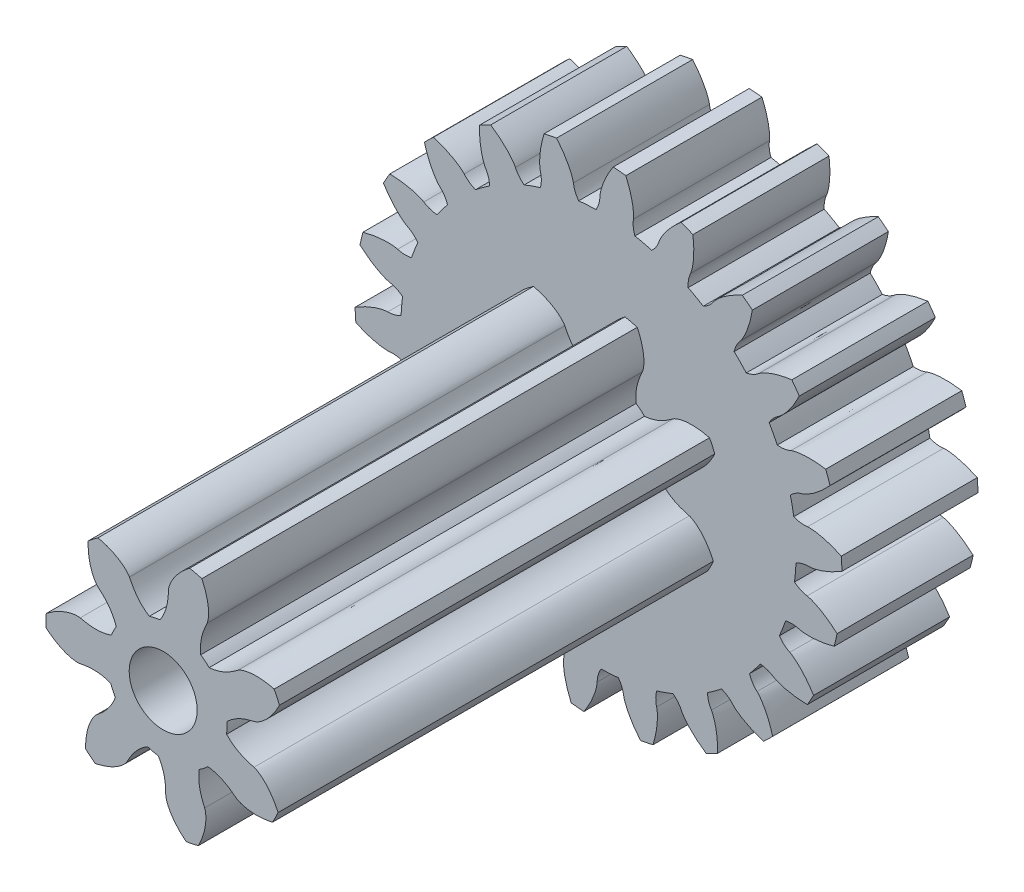
from build123d import *

# Parameters (mm, degrees)
EXTRUDE_1_DEPTH     = 10
EXTRUDE_2_DEPTH     = 32
SKETCH_5_R          = 2.5
CUT_EXTRUDE_1_DEPTH = 42


with BuildPart() as part:
    # 草图3 → 凸台-拉伸1 (new body)
    with BuildSketch(Plane.XY):
        with BuildLine():
            ThreePointArc((-8.005629463, 12.119633736), (-8.530243258, 11.756299373), (-9.038391722, 11.370272648))
            add(Edge.make_bspline(
                [(-9.038391722, 11.370272648), (-9.199749688, 11.431587767), (-9.351710074, 11.509202907), (-9.633739232, 11.702404006), (-9.763643975, 11.818787161), (-9.875892363, 11.950349138)],
                knots=[0, 0, 0, 0, 0.5, 0.5, 1, 1, 1, 1], degree=3))
            add(Edge.make_bspline(
                [(-9.875892363, 11.950349138), (-9.911367886, 11.991928621), (-9.950605534, 12.028738211), (-10.030196962, 12.100942279), (-10.071171913, 12.135549192), (-10.196572985, 12.2362304), (-10.283429657, 12.29922307), (-10.55106675, 12.47924093), (-10.738275466, 12.586937348), (-11.312628385, 12.880499231), (-11.714900374, 13.038200827), (-12.126147124, 13.16687343)],
                knots=[0, 0, 0, 0, 0.0625, 0.0625, 0.125, 0.125, 0.25, 0.25, 0.5, 0.5, 1, 1, 1, 1], degree=3))
            ThreePointArc((-12.126147124, 13.16687343), (-12.46716641, 12.84444478), (-12.799615589, 12.513186675))
            add(Edge.make_bspline(
                [(-12.799615589, 12.513186675), (-12.683196746, 12.098072887), (-12.53754001, 11.691181633), (-12.260711625, 11.107480816), (-12.158558163, 10.917204496), (-11.987275836, 10.645454457), (-11.927080489, 10.557003244), (-11.830304905, 10.428783255), (-11.796951142, 10.386796244), (-11.727094074, 10.304987565), (-11.691435842, 10.2645849), (-11.650698485, 10.227674188)],
                knots=[0, 0, 0, 0, 0.5, 0.5, 0.75, 0.75, 0.875, 0.875, 0.9375, 0.9375, 1, 1, 1, 1], degree=3))
            add(Edge.make_bspline(
                [(-11.650698485, 10.227674188), (-11.522536977, 10.111551468), (-11.412476818, 9.981355023), (-11.227133323, 9.693923293), (-11.152382825, 9.536553925), (-11.09584062, 9.373256955)],
                knots=[0, 0, 0, 0, 0.5, 0.5, 1, 1, 1, 1], degree=3))
            ThreePointArc((-11.09584062, 9.373256955), (-11.496840751, 8.876839401), (-11.875649335, 8.363287504))
            add(Edge.make_bspline(
                [(-11.875649335, 8.363287504), (-12.047745635, 8.376659138), (-12.21541727, 8.408318131), (-12.540453305, 8.514236432), (-12.697884916, 8.589306856), (-12.842651749, 8.683915623)],
                knots=[0, 0, 0, 0, 0.5, 0.5, 1, 1, 1, 1], degree=3))
            add(Edge.make_bspline(
                [(-12.842651749, 8.683915623), (-12.888404557, 8.713816235), (-12.936423265, 8.738080255), (-13.033132917, 8.784936055), (-13.082197989, 8.806597167), (-13.230884611, 8.867870514), (-13.331970063, 8.903841186), (-13.639482865, 9.001164976), (-13.849449901, 9.051756142), (-14.48324343, 9.17161279), (-14.913650252, 9.209593247), (-15.34448988, 9.217192107)],
                knots=[0, 0, 0, 0, 0.0625, 0.0625, 0.125, 0.125, 0.25, 0.25, 0.5, 0.5, 1, 1, 1, 1], degree=3))
            ThreePointArc((-15.34448988, 9.217192107), (-15.580856841, 8.811747847), (-15.806513299, 8.400246266))
            add(Edge.make_bspline(
                [(-15.806513299, 8.400246266), (-15.577859168, 8.034746481), (-15.32346804, 7.685373426), (-14.893405626, 7.203308163), (-14.741783063, 7.049519327), (-14.50087804, 6.837032881), (-14.418201441, 6.769123553), (-14.289222203, 6.673362207), (-14.245390394, 6.642472806), (-14.15531486, 6.583658964), (-14.109718291, 6.554938976), (-14.060232134, 6.531000446)],
                knots=[0, 0, 0, 0, 0.5, 0.5, 0.75, 0.75, 0.875, 0.875, 0.9375, 0.9375, 1, 1, 1, 1], degree=3))
            add(Edge.make_bspline(
                [(-14.060232134, 6.531000446), (-13.904546516, 6.455688782), (-13.76226399, 6.361773737), (-13.503449332, 6.138202309), (-13.387390681, 6.008267155), (-13.287132759, 5.86751464)],
                knots=[0, 0, 0, 0, 0.5, 0.5, 1, 1, 1, 1], degree=3))
            ThreePointArc((-13.287132759, 5.86751464), (-13.532032581, 5.278230692), (-13.750812466, 4.678758546))
            add(Edge.make_bspline(
                [(-13.750812466, 4.678758546), (-13.919704881, 4.643103404), (-14.089504006, 4.626241426), (-14.431214431, 4.636296059), (-14.603418739, 4.663971993), (-14.768975867, 4.713962911)],
                knots=[0, 0, 0, 0, 0.5, 0.5, 1, 1, 1, 1], degree=3))
            add(Edge.make_bspline(
                [(-14.768975867, 4.713962911), (-14.821299342, 4.729762282), (-14.874208918, 4.739515005), (-14.980201955, 4.757226558), (-15.033382186, 4.764187015), (-15.193308653, 4.781088498), (-15.300433543, 4.787123042), (-15.622909196, 4.793868167), (-15.83862427, 4.783255485), (-16.480512228, 4.719696825), (-16.90418488, 4.634879193), (-17.319713322, 4.520788695)],
                knots=[0, 0, 0, 0, 0.0625, 0.0625, 0.125, 0.125, 0.25, 0.25, 0.5, 0.5, 1, 1, 1, 1], degree=3))
            ThreePointArc((-17.319713322, 4.520788695), (-17.432278913, 4.065175509), (-17.532861306, 3.606767863))
            add(Edge.make_bspline(
                [(-17.532861306, 3.606767863), (-17.210496085, 3.3204927), (-16.867979821, 3.056941972), (-16.319524478, 2.715566322), (-16.130716372, 2.610724027), (-15.839705346, 2.474715564), (-15.741245461, 2.43284973), (-15.5905117, 2.377305042), (-15.539752837, 2.360015726), (-15.436756221, 2.328961468), (-15.384915278, 2.31425088), (-15.330689394, 2.30522389)],
                knots=[0, 0, 0, 0, 0.5, 0.5, 0.75, 0.75, 0.875, 0.875, 0.9375, 0.9375, 1, 1, 1, 1], degree=3))
            add(Edge.make_bspline(
                [(-15.330689394, 2.30522389), (-15.16009239, 2.276824585), (-14.99711438, 2.226799379), (-14.685796185, 2.08520068), (-14.537831761, 1.993226313), (-14.401980423, 1.886421184)],
                knots=[0, 0, 0, 0, 0.5, 0.5, 1, 1, 1, 1], degree=3))
            ThreePointArc((-14.401980423, 1.886421184), (-14.470939608, 1.252011124), (-14.51196655, 0.615184395))
            add(Edge.make_bspline(
                [(-14.51196655, 0.615184395), (-14.663972422, 0.533391045), (-14.822142921, 0.469374155), (-15.152844391, 0.382750552), (-15.325870425, 0.360789857), (-15.498805396, 0.362112958)],
                knots=[0, 0, 0, 0, 0.5, 0.5, 1, 1, 1, 1], degree=3))
            add(Edge.make_bspline(
                [(-15.498805396, 0.362112958), (-15.553460599, 0.362531117), (-15.606974626, 0.356982436), (-15.713664121, 0.344114858), (-15.766651166, 0.335810764), (-15.924861185, 0.306971127), (-16.029346892, 0.28258066), (-16.340660337, 0.19820067), (-16.544647496, 0.127243917), (-17.142627938, -0.114580906), (-17.525242983, -0.315325208), (-17.891796596, -0.54186213)],
                knots=[0, 0, 0, 0, 0.0625, 0.0625, 0.125, 0.125, 0.25, 0.25, 0.5, 0.5, 1, 1, 1, 1], degree=3))
            ThreePointArc((-17.891796596, -0.54186213), (-17.871441421, -1.010733172), (-17.838801163, -1.478909423))
            add(Edge.make_bspline(
                [(-17.838801163, -1.478909423), (-17.448840964, -1.662767652), (-17.045948195, -1.819144741), (-16.423532512, -1.992174552), (-16.212834973, -2.039576607), (-15.895293926, -2.088088492), (-15.789027391, -2.10051911), (-15.628750659, -2.11134724), (-15.575176923, -2.113635793), (-15.467603398, -2.114414635), (-15.413717926, -2.11392406), (-15.359145375, -2.107308196)],
                knots=[0, 0, 0, 0, 0.5, 0.5, 0.75, 0.75, 0.875, 0.875, 0.9375, 0.9375, 1, 1, 1, 1], degree=3))
            add(Edge.make_bspline(
                [(-15.359145375, -2.107308196), (-15.18745774, -2.0864944), (-15.016987755, -2.088577021), (-14.678387171, -2.136731507), (-14.510504172, -2.18329387), (-14.350065286, -2.247498897)],
                knots=[0, 0, 0, 0, 0.5, 0.5, 1, 1, 1, 1], degree=3))
            ThreePointArc((-14.350065286, -2.247498897), (-14.237497171, -2.875638939), (-14.097447411, -3.498228337))
            add(Edge.make_bspline(
                [(-14.097447411, -3.498228337), (-14.220252127, -3.619533484), (-14.353979967, -3.72551902), (-14.646881015, -3.901803128), (-14.806711236, -3.971621328), (-14.973013886, -4.019073234)],
                knots=[0, 0, 0, 0, 0.5, 0.5, 1, 1, 1, 1], degree=3))
            add(Edge.make_bspline(
                [(-14.973013886, -4.019073234), (-15.025572979, -4.034070163), (-15.075356068, -4.054470727), (-15.174098672, -4.096874982), (-15.222599837, -4.119770877), (-15.366276173, -4.19201522), (-15.459657887, -4.244854727), (-15.734588359, -4.413523867), (-15.910321778, -4.539076197), (-16.415949884, -4.939575975), (-16.726510126, -5.239983837), (-17.014392916, -5.560614507)],
                knots=[0, 0, 0, 0, 0.0625, 0.0625, 0.125, 0.125, 0.25, 0.25, 0.5, 0.5, 1, 1, 1, 1], degree=3))
            ThreePointArc((-17.014392916, -5.560614507), (-16.862766031, -6.004758263), (-16.69954744, -6.444774263))
            add(Edge.make_bspline(
                [(-16.69954744, -6.444774263), (-16.273584521, -6.511320458), (-15.842955223, -6.547855166), (-15.197003617, -6.538521292), (-14.981486107, -6.524642874), (-14.663140326, -6.481728036), (-14.557676222, -6.463716384), (-14.400841187, -6.428950725), (-14.348792805, -6.41605311), (-14.245357338, -6.386493439), (-14.193792817, -6.370841444), (-14.143294742, -6.349118705)],
                knots=[0, 0, 0, 0, 0.5, 0.5, 0.75, 0.75, 0.875, 0.875, 0.9375, 0.9375, 1, 1, 1, 1], degree=3))
            add(Edge.make_bspline(
                [(-14.143294742, -6.349118705), (-13.984425586, -6.280778017), (-13.820274091, -6.234749333), (-13.481822523, -6.185558416), (-13.307621832, -6.182936569), (-13.135593202, -6.199339983)],
                knots=[0, 0, 0, 0, 0.5, 0.5, 1, 1, 1, 1], degree=3))
            ThreePointArc((-13.135593202, -6.199339983), (-12.850617387, -6.770321838), (-12.540836923, -7.328235413))
            add(Edge.make_bspline(
                [(-12.540836923, -7.328235413), (-12.624491576, -7.479224937), (-12.722942923, -7.6185928), (-12.954314447, -7.870255924), (-13.088000362, -7.982275374), (-13.234197839, -8.074658014)],
                knots=[0, 0, 0, 0, 0.5, 0.5, 1, 1, 1, 1], degree=3))
            add(Edge.make_bspline(
                [(-13.234197839, -8.074658014), (-13.280402796, -8.10385507), (-13.322421817, -8.137454784), (-13.405217993, -8.205960376), (-13.445304001, -8.241593183), (-13.562806853, -8.351389424), (-13.637519341, -8.428397229), (-13.853793609, -8.667690949), (-13.987036411, -8.837667352), (-14.3593492, -9.364395974), (-14.572694895, -9.740130138), (-14.75858431, -10.128878968)],
                knots=[0, 0, 0, 0, 0.0625, 0.0625, 0.125, 0.125, 0.25, 0.25, 0.5, 0.5, 1, 1, 1, 1], degree=3))
            ThreePointArc((-14.75858431, -10.128878968), (-14.487969623, -10.512313551), (-14.2073957, -10.88852182))
            add(Edge.make_bspline(
                [(-14.2073957, -10.88852182), (-13.779939042, -10.832364805), (-13.35646024, -10.746097307), (-12.739303869, -10.555155923), (-12.536426334, -10.481121379), (-12.243066302, -10.350256523), (-12.146948704, -10.303261797), (-12.006261207, -10.225718857), (-11.959954828, -10.198679962), (-11.869037147, -10.141176527), (-11.823971028, -10.111631143), (-11.781638482, -10.076561376)],
                knots=[0, 0, 0, 0, 0.5, 0.5, 0.75, 0.75, 0.875, 0.875, 0.9375, 0.9375, 1, 1, 1, 1], degree=3))
            add(Edge.make_bspline(
                [(-11.781638482, -10.076561376), (-11.64845844, -9.966230353), (-11.503924013, -9.875819334), (-11.193040795, -9.733268168), (-11.026635115, -9.681674519), (-10.856953477, -9.648947414)],
                knots=[0, 0, 0, 0, 0.5, 0.5, 1, 1, 1, 1], degree=3))
            ThreePointArc((-10.856953477, -9.648947414), (-10.422657007, -10.116513526), (-9.968242411, -10.564552439))
            add(Edge.make_bspline(
                [(-9.968242411, -10.564552439), (-10.005969798, -10.732994065), (-10.061168709, -10.8944535), (-10.212266366, -11.201107391), (-10.308977536, -11.34625294), (-10.42322579, -11.476082024)],
                knots=[0, 0, 0, 0, 0.5, 0.5, 1, 1, 1, 1], degree=3))
            add(Edge.make_bspline(
                [(-10.42322579, -11.476082024), (-10.45933336, -11.517113834), (-10.490184183, -11.56119065), (-10.550326276, -11.650247663), (-10.578749597, -11.695730625), (-10.660559582, -11.834183725), (-10.710550084, -11.929121113), (-10.850646893, -12.219653259), (-10.930604538, -12.420283259), (-11.139439442, -13.030568304), (-11.23828659, -13.451189022), (-11.307122977, -13.876561894)],
                knots=[0, 0, 0, 0, 0.0625, 0.0625, 0.125, 0.125, 0.25, 0.25, 0.5, 0.5, 1, 1, 1, 1], degree=3))
            ThreePointArc((-11.307122977, -13.876561894), (-10.939444081, -14.168223714), (-10.564245255, -14.450146096))
            add(Edge.make_bspline(
                [(-10.564245255, -14.450146096), (-10.169924855, -14.275835377), (-9.787904282, -14.073754553), (-9.249541485, -13.716674595), (-9.075739857, -13.588481764), (-8.831131858, -13.380268782), (-8.752147642, -13.308098216), (-8.639005349, -13.194060061), (-8.60219244, -13.155070417), (-8.531158153, -13.074281804), (-8.496241425, -13.033236623), (-8.46550394, -12.987660972)],
                knots=[0, 0, 0, 0, 0.5, 0.5, 0.75, 0.75, 0.875, 0.875, 0.9375, 0.9375, 1, 1, 1, 1], degree=3))
            add(Edge.make_bspline(
                [(-8.46550394, -12.987660972), (-8.368802467, -12.844277977), (-8.255594428, -12.716809185), (-7.997465468, -12.49244642), (-7.852335998, -12.396060778), (-7.698747951, -12.316854509)],
                knots=[0, 0, 0, 0, 0.5, 0.5, 1, 1, 1, 1], degree=3))
            ThreePointArc((-7.698747951, -12.316854509), (-7.150314943, -12.643125453), (-6.588080182, -12.944992257))
            add(Edge.make_bspline(
                [(-6.588080182, -12.944992257), (-6.576823855, -13.117239846), (-6.584298443, -13.28771037), (-6.642881198, -13.624511753), (-6.694782659, -13.791024573), (-6.767825977, -13.947782119)],
                knots=[0, 0, 0, 0, 0.5, 0.5, 1, 1, 1, 1], degree=3))
            add(Edge.make_bspline(
                [(-6.767825977, -13.947782119), (-6.79091094, -13.997324531), (-6.808094213, -14.048307607), (-6.84070987, -14.15070117), (-6.855167815, -14.202349528), (-6.894657175, -14.358242841), (-6.915875758, -14.463418549), (-6.968445297, -14.781651934), (-6.988640093, -14.996681681), (-7.017078549, -15.641081486), (-6.993419143, -16.072512569), (-6.939625785, -16.500048302)],
                knots=[0, 0, 0, 0, 0.0625, 0.0625, 0.125, 0.125, 0.25, 0.25, 0.5, 0.5, 1, 1, 1, 1], degree=3))
            ThreePointArc((-6.939625785, -16.500048302), (-6.504669838, -16.676308653), (-6.065242487, -16.841105473))
            add(Edge.make_bspline(
                [(-6.065242487, -16.841105473), (-5.736003839, -16.562762669), (-5.42639053, -16.261239906), (-5.010436259, -15.766949868), (-4.879790912, -15.59498417), (-4.703751632, -15.326291239), (-4.64829963, -15.234791664), (-4.571868655, -15.093496988), (-4.54753158, -15.045715303), (-4.502135463, -14.948186526), (-4.480196872, -14.898966784), (-4.463544616, -14.846577516)],
                knots=[0, 0, 0, 0, 0.5, 0.5, 0.75, 0.75, 0.875, 0.875, 0.9375, 0.9375, 1, 1, 1, 1], degree=3))
            add(Edge.make_bspline(
                [(-4.463544616, -14.846577516), (-4.41115589, -14.681758587), (-4.33844568, -14.527558786), (-4.153983053, -14.239560957), (-4.041887319, -14.106191915), (-3.916835651, -13.986923303)],
                knots=[0, 0, 0, 0, 0.5, 0.5, 1, 1, 1, 1], degree=3))
            ThreePointArc((-3.916835651, -13.986923303), (-3.298696886, -14.145466548), (-2.674190877, -14.276705788))
            add(Edge.make_bspline(
                [(-2.674190877, -14.276705788), (-2.614862757, -14.438804866), (-2.574007475, -14.604475971), (-2.535329302, -14.9441392), (-2.538216307, -15.118529412), (-2.564137153, -15.289515857)],
                knots=[0, 0, 0, 0, 0.5, 0.5, 1, 1, 1, 1], degree=3))
            add(Edge.make_bspline(
                [(-2.564137153, -15.289515857), (-2.572329302, -15.343555239), (-2.57445294, -15.39731423), (-2.576899832, -15.504749027), (-2.576221106, -15.558378537), (-2.570190648, -15.719082514), (-2.560918307, -15.825975832), (-2.521701706, -16.14612908), (-2.48049759, -16.358138143), (-2.326235685, -16.984447267), (-2.181986468, -17.391736735), (-2.009921385, -17.786798926)],
                knots=[0, 0, 0, 0, 0.0625, 0.0625, 0.125, 0.125, 0.25, 0.25, 0.5, 0.5, 1, 1, 1, 1], degree=3))
            ThreePointArc((-2.009921385, -17.786798926), (-1.542925929, -17.833378244), (-1.074869845, -17.867698644))
            add(Edge.make_bspline(
                [(-1.074869845, -17.867698644), (-0.837385905, -17.507873432), (-0.62526289, -17.131336311), (-0.365415286, -16.539880631), (-0.288510329, -16.338073705), (-0.195301423, -16.030668729), (-0.167874025, -15.927252895), (-0.134346353, -15.770148553), (-0.124456757, -15.717445816), (-0.108376533, -15.611078075), (-0.101193413, -15.557671263), (-0.099975453, -15.502712646)],
                knots=[0, 0, 0, 0, 0.5, 0.5, 0.75, 0.75, 0.875, 0.875, 0.9375, 0.9375, 1, 1, 1, 1], degree=3))
            add(Edge.make_bspline(
                [(-0.099975453, -15.502712646), (-0.096143696, -15.329810432), (-0.069821865, -15.161371973), (0.026030365, -14.833070953), (0.096011032, -14.673523276), (0.182395378, -14.523854755)],
                knots=[0, 0, 0, 0, 0.5, 0.5, 1, 1, 1, 1], degree=3))
            ThreePointArc((0.182395378, -14.523854755), (0.820161974, -14.501826069), (1.456345468, -14.451805523))
            add(Edge.make_bspline(
                [(1.456345468, -14.451805523), (1.558938971, -14.590623787), (1.64481427, -14.738073785), (1.777619896, -15.053081366), (1.823981235, -15.221220913), (1.847282814, -15.392583951)],
                knots=[0, 0, 0, 0, 0.5, 0.5, 1, 1, 1, 1], degree=3))
            add(Edge.make_bspline(
                [(1.847282814, -15.392583951), (1.854647157, -15.446742354), (1.8677552, -15.498922025), (1.895675304, -15.602694327), (1.911435716, -15.653960246), (1.962497441, -15.806455606), (2.001509514, -15.906406674), (2.129335161, -16.202542872), (2.228600076, -16.394355538), (2.553064961, -16.951834141), (2.806217773, -17.301985823), (3.082614893, -17.632568883)],
                knots=[0, 0, 0, 0, 0.0625, 0.0625, 0.125, 0.125, 0.25, 0.25, 0.5, 0.5, 1, 1, 1, 1], degree=3))
            ThreePointArc((3.082614893, -17.632568883), (3.543816662, -17.545693588), (4.00258236, -17.446757133))
            add(Edge.make_bspline(
                [(4.00258236, -17.446757133), (4.129072055, -17.034600413), (4.226519831, -16.613553731), (4.309209461, -15.972848633), (4.326143645, -15.757549675), (4.328970946, -15.436336777), (4.326151734, -15.32938282), (4.314059892, -15.169196471), (4.308700813, -15.115842344), (4.294162419, -15.009252921), (4.286008135, -14.955985742), (4.271693127, -14.902910196)],
                knots=[0, 0, 0, 0, 0.5, 0.5, 0.75, 0.75, 0.875, 0.875, 0.9375, 0.9375, 1, 1, 1, 1], degree=3))
            add(Edge.make_bspline(
                [(4.271693127, -14.902910196), (4.226657488, -14.735932205), (4.204458503, -14.566900971), (4.203934958, -14.224893755), (4.226131141, -14.052093048), (4.266849819, -13.88414987)],
                knots=[0, 0, 0, 0, 0.5, 0.5, 1, 1, 1, 1], degree=3))
            ThreePointArc((4.266849819, -13.88414987), (4.872576188, -13.683333888), (5.468897364, -13.456105923))
            add(Edge.make_bspline(
                [(5.468897364, -13.456105923), (5.606444734, -13.560397142), (5.730382945, -13.677680511), (5.946556901, -13.942512404), (6.038410665, -14.090779619), (6.109046913, -14.248636437)],
                knots=[0, 0, 0, 0, 0.5, 0.5, 1, 1, 1, 1], degree=3))
            add(Edge.make_bspline(
                [(6.109046913, -14.248636437), (6.131371134, -14.298526268), (6.158648921, -14.344899334), (6.2146741, -14.436602126), (6.244239384, -14.481351194), (6.336195658, -14.61328367), (6.401786938, -14.698195047), (6.607865956, -14.946323002), (6.757149817, -15.102399748), (7.225531467, -15.545884229), (7.56707894, -15.810530918), (7.925416046, -16.049852974)],
                knots=[0, 0, 0, 0, 0.0625, 0.0625, 0.125, 0.125, 0.25, 0.25, 0.5, 0.5, 1, 1, 1, 1], degree=3))
            ThreePointArc((7.925416046, -16.049852974), (8.343460303, -15.836561185), (8.755769146, -15.612383119))
            add(Edge.make_bspline(
                [(8.755769146, -15.612383119), (8.761017154, -15.181285377), (8.735895052, -14.749839833), (8.634727685, -14.111791432), (8.59031919, -13.900442684), (8.502535835, -13.591444623), (8.469698408, -13.489617317), (8.412966661, -13.339326305), (8.392793068, -13.289643222), (8.34881387, -13.19146736), (8.325982793, -13.142655202), (8.297294535, -13.095762593)],
                knots=[0, 0, 0, 0, 0.5, 0.5, 0.75, 0.75, 0.875, 0.875, 0.9375, 0.9375, 1, 1, 1, 1], degree=3))
            add(Edge.make_bspline(
                [(8.297294535, -13.095762593), (8.207040019, -12.94823639), (8.138118647, -12.792306285), (8.041261742, -12.464300264), (8.013875239, -12.292245812), (8.005629463, -12.119633736)],
                knots=[0, 0, 0, 0, 0.5, 0.5, 1, 1, 1, 1], degree=3))
            ThreePointArc((8.005629463, -12.119633736), (8.530243259, -11.756299373), (9.038391722, -11.370272648))
            add(Edge.make_bspline(
                [(9.038391722, -11.370272648), (9.199749688, -11.431587767), (9.351710074, -11.509202907), (9.633739232, -11.702404006), (9.763643975, -11.818787161), (9.875892363, -11.950349138)],
                knots=[0, 0, 0, 0, 0.5, 0.5, 1, 1, 1, 1], degree=3))
            add(Edge.make_bspline(
                [(9.875892363, -11.950349138), (9.911367886, -11.991928621), (9.950605534, -12.028738211), (10.030196962, -12.100942279), (10.071171913, -12.135549191), (10.196572985, -12.2362304), (10.283429657, -12.29922307), (10.55106675, -12.47924093), (10.738275466, -12.586937348), (11.312628385, -12.880499231), (11.714900374, -13.038200827), (12.126147124, -13.16687343)],
                knots=[0, 0, 0, 0, 0.0625, 0.0625, 0.125, 0.125, 0.25, 0.25, 0.5, 0.5, 1, 1, 1, 1], degree=3))
            ThreePointArc((12.126147124, -13.16687343), (12.46716641, -12.84444478), (12.799615589, -12.513186675))
            add(Edge.make_bspline(
                [(12.799615589, -12.513186675), (12.683196746, -12.098072887), (12.53754001, -11.691181633), (12.260711625, -11.107480816), (12.158558163, -10.917204496), (11.987275836, -10.645454457), (11.927080489, -10.557003244), (11.830304905, -10.428783255), (11.796951142, -10.386796244), (11.727094074, -10.304987565), (11.691435842, -10.2645849), (11.650698485, -10.227674188)],
                knots=[0, 0, 0, 0, 0.5, 0.5, 0.75, 0.75, 0.875, 0.875, 0.9375, 0.9375, 1, 1, 1, 1], degree=3))
            add(Edge.make_bspline(
                [(11.650698485, -10.227674188), (11.522536977, -10.111551468), (11.412476818, -9.981355023), (11.227133323, -9.693923293), (11.152382825, -9.536553925), (11.09584062, -9.373256955)],
                knots=[0, 0, 0, 0, 0.5, 0.5, 1, 1, 1, 1], degree=3))
            ThreePointArc((11.09584062, -9.373256955), (11.496840751, -8.876839401), (11.875649335, -8.363287504))
            add(Edge.make_bspline(
                [(11.875649335, -8.363287504), (12.047745635, -8.376659138), (12.21541727, -8.408318131), (12.540453305, -8.514236432), (12.697884916, -8.589306856), (12.842651749, -8.683915624)],
                knots=[0, 0, 0, 0, 0.5, 0.5, 1, 1, 1, 1], degree=3))
            add(Edge.make_bspline(
                [(12.842651749, -8.683915624), (12.888404557, -8.713816235), (12.936423265, -8.738080255), (13.033132917, -8.784936055), (13.082197989, -8.806597167), (13.230884611, -8.867870514), (13.331970063, -8.903841186), (13.639482865, -9.001164976), (13.849449901, -9.051756142), (14.48324343, -9.17161279), (14.913650252, -9.209593247), (15.34448988, -9.217192107)],
                knots=[0, 0, 0, 0, 0.0625, 0.0625, 0.125, 0.125, 0.25, 0.25, 0.5, 0.5, 1, 1, 1, 1], degree=3))
            ThreePointArc((15.34448988, -9.217192107), (15.580856841, -8.811747847), (15.806513299, -8.400246266))
            add(Edge.make_bspline(
                [(15.806513299, -8.400246266), (15.577859168, -8.034746481), (15.32346804, -7.685373426), (14.893405626, -7.203308163), (14.741783063, -7.049519327), (14.50087804, -6.837032881), (14.418201441, -6.769123553), (14.289222203, -6.673362207), (14.245390394, -6.642472806), (14.15531486, -6.583658964), (14.109718291, -6.554938976), (14.060232134, -6.531000446)],
                knots=[0, 0, 0, 0, 0.5, 0.5, 0.75, 0.75, 0.875, 0.875, 0.9375, 0.9375, 1, 1, 1, 1], degree=3))
            add(Edge.make_bspline(
                [(14.060232134, -6.531000446), (13.904546516, -6.455688782), (13.76226399, -6.361773737), (13.503449332, -6.138202309), (13.387390681, -6.008267155), (13.287132759, -5.86751464)],
                knots=[0, 0, 0, 0, 0.5, 0.5, 1, 1, 1, 1], degree=3))
            ThreePointArc((13.287132759, -5.86751464), (13.532032581, -5.278230692), (13.750812466, -4.678758545))
            add(Edge.make_bspline(
                [(13.750812466, -4.678758545), (13.919704881, -4.643103403), (14.089504006, -4.626241426), (14.431214431, -4.636296059), (14.603418739, -4.663971993), (14.768975867, -4.71396291)],
                knots=[0, 0, 0, 0, 0.5, 0.5, 1, 1, 1, 1], degree=3))
            add(Edge.make_bspline(
                [(14.768975867, -4.71396291), (14.821299342, -4.729762281), (14.874208919, -4.739515005), (14.980201955, -4.757226558), (15.033382186, -4.764187015), (15.193308653, -4.781088498), (15.300433543, -4.787123042), (15.622909196, -4.793868167), (15.83862427, -4.783255485), (16.480512228, -4.719696825), (16.90418488, -4.634879193), (17.319713322, -4.520788695)],
                knots=[0, 0, 0, 0, 0.0625, 0.0625, 0.125, 0.125, 0.25, 0.25, 0.5, 0.5, 1, 1, 1, 1], degree=3))
            ThreePointArc((17.319713322, -4.520788695), (17.432278913, -4.065175509), (17.532861306, -3.606767863))
            add(Edge.make_bspline(
                [(17.532861306, -3.606767863), (17.210496085, -3.3204927), (16.867979821, -3.056941972), (16.319524478, -2.715566322), (16.130716372, -2.610724027), (15.839705346, -2.474715563), (15.741245461, -2.43284973), (15.5905117, -2.377305041), (15.539752837, -2.360015726), (15.436756221, -2.328961468), (15.384915278, -2.31425088), (15.330689394, -2.30522389)],
                knots=[0, 0, 0, 0, 0.5, 0.5, 0.75, 0.75, 0.875, 0.875, 0.9375, 0.9375, 1, 1, 1, 1], degree=3))
            add(Edge.make_bspline(
                [(15.330689394, -2.30522389), (15.16009239, -2.276824585), (14.99711438, -2.226799379), (14.685796185, -2.08520068), (14.537831761, -1.993226313), (14.401980424, -1.886421184)],
                knots=[0, 0, 0, 0, 0.5, 0.5, 1, 1, 1, 1], degree=3))
            ThreePointArc((14.401980424, -1.886421184), (14.470939608, -1.252011124), (14.511966551, -0.615184395))
            add(Edge.make_bspline(
                [(14.511966551, -0.615184395), (14.663972422, -0.533391045), (14.822142921, -0.469374154), (15.152844391, -0.382750552), (15.325870425, -0.360789857), (15.498805396, -0.362112957)],
                knots=[0, 0, 0, 0, 0.5, 0.5, 1, 1, 1, 1], degree=3))
            add(Edge.make_bspline(
                [(15.498805396, -0.362112957), (15.553460599, -0.362531117), (15.606974626, -0.356982436), (15.713664121, -0.344114858), (15.766651166, -0.335810764), (15.924861185, -0.306971127), (16.029346892, -0.28258066), (16.340660337, -0.19820067), (16.544647496, -0.127243917), (17.142627938, 0.114580906), (17.525242983, 0.315325208), (17.891796596, 0.54186213)],
                knots=[0, 0, 0, 0, 0.0625, 0.0625, 0.125, 0.125, 0.25, 0.25, 0.5, 0.5, 1, 1, 1, 1], degree=3))
            ThreePointArc((17.891796596, 0.54186213), (17.871441421, 1.010733172), (17.838801163, 1.478909423))
            add(Edge.make_bspline(
                [(17.838801163, 1.478909423), (17.448840964, 1.662767652), (17.045948195, 1.819144741), (16.423532512, 1.992174552), (16.212834973, 2.039576607), (15.895293926, 2.088088492), (15.789027391, 2.10051911), (15.628750659, 2.11134724), (15.575176923, 2.113635793), (15.467603398, 2.114414635), (15.413717926, 2.11392406), (15.359145375, 2.107308196)],
                knots=[0, 0, 0, 0, 0.5, 0.5, 0.75, 0.75, 0.875, 0.875, 0.9375, 0.9375, 1, 1, 1, 1], degree=3))
            add(Edge.make_bspline(
                [(15.359145375, 2.107308196), (15.18745774, 2.0864944), (15.016987755, 2.088577021), (14.67838717, 2.136731507), (14.510504172, 2.18329387), (14.350065286, 2.247498897)],
                knots=[0, 0, 0, 0, 0.5, 0.5, 1, 1, 1, 1], degree=3))
            ThreePointArc((14.350065286, 2.247498897), (14.237497171, 2.875638939), (14.097447411, 3.498228337))
            add(Edge.make_bspline(
                [(14.097447411, 3.498228337), (14.220252127, 3.619533484), (14.353979967, 3.72551902), (14.646881015, 3.901803128), (14.806711236, 3.971621329), (14.973013886, 4.019073234)],
                knots=[0, 0, 0, 0, 0.5, 0.5, 1, 1, 1, 1], degree=3))
            add(Edge.make_bspline(
                [(14.973013886, 4.019073234), (15.025572979, 4.034070163), (15.075356068, 4.054470727), (15.174098672, 4.096874982), (15.222599837, 4.119770877), (15.366276173, 4.19201522), (15.459657887, 4.244854727), (15.734588359, 4.413523868), (15.910321778, 4.539076197), (16.415949884, 4.939575975), (16.726510126, 5.239983837), (17.014392916, 5.560614508)],
                knots=[0, 0, 0, 0, 0.0625, 0.0625, 0.125, 0.125, 0.25, 0.25, 0.5, 0.5, 1, 1, 1, 1], degree=3))
            ThreePointArc((17.014392916, 5.560614508), (16.862766031, 6.004758263), (16.69954744, 6.444774263))
            add(Edge.make_bspline(
                [(16.69954744, 6.444774263), (16.273584521, 6.511320458), (15.842955223, 6.547855166), (15.197003617, 6.538521292), (14.981486107, 6.524642874), (14.663140326, 6.481728036), (14.557676222, 6.463716384), (14.400841187, 6.428950725), (14.348792805, 6.41605311), (14.245357338, 6.386493439), (14.193792817, 6.370841444), (14.143294742, 6.349118705)],
                knots=[0, 0, 0, 0, 0.5, 0.5, 0.75, 0.75, 0.875, 0.875, 0.9375, 0.9375, 1, 1, 1, 1], degree=3))
            add(Edge.make_bspline(
                [(14.143294742, 6.349118705), (13.984425586, 6.280778017), (13.820274091, 6.234749333), (13.481822523, 6.185558416), (13.307621832, 6.182936569), (13.135593202, 6.199339983)],
                knots=[0, 0, 0, 0, 0.5, 0.5, 1, 1, 1, 1], degree=3))
            ThreePointArc((13.135593202, 6.199339983), (12.850617387, 6.770321838), (12.540836923, 7.328235413))
            add(Edge.make_bspline(
                [(12.540836923, 7.328235413), (12.624491576, 7.479224937), (12.722942923, 7.6185928), (12.954314447, 7.870255924), (13.088000362, 7.982275373), (13.234197839, 8.074658014)],
                knots=[0, 0, 0, 0, 0.5, 0.5, 1, 1, 1, 1], degree=3))
            add(Edge.make_bspline(
                [(13.234197839, 8.074658014), (13.280402796, 8.10385507), (13.322421817, 8.137454784), (13.405217993, 8.205960376), (13.445304001, 8.241593183), (13.562806853, 8.351389424), (13.637519341, 8.428397229), (13.853793609, 8.667690949), (13.987036411, 8.837667352), (14.3593492, 9.364395974), (14.572694895, 9.740130138), (14.75858431, 10.128878968)],
                knots=[0, 0, 0, 0, 0.0625, 0.0625, 0.125, 0.125, 0.25, 0.25, 0.5, 0.5, 1, 1, 1, 1], degree=3))
            ThreePointArc((14.75858431, 10.128878968), (14.487969623, 10.512313551), (14.2073957, 10.88852182))
            add(Edge.make_bspline(
                [(14.2073957, 10.88852182), (13.779939042, 10.832364805), (13.35646024, 10.746097307), (12.739303869, 10.555155923), (12.536426334, 10.481121379), (12.243066302, 10.350256523), (12.146948704, 10.303261797), (12.006261207, 10.225718857), (11.959954828, 10.198679962), (11.869037147, 10.141176527), (11.823971028, 10.111631143), (11.781638482, 10.076561376)],
                knots=[0, 0, 0, 0, 0.5, 0.5, 0.75, 0.75, 0.875, 0.875, 0.9375, 0.9375, 1, 1, 1, 1], degree=3))
            add(Edge.make_bspline(
                [(11.781638482, 10.076561376), (11.64845844, 9.966230353), (11.503924013, 9.875819334), (11.193040795, 9.733268168), (11.026635115, 9.681674519), (10.856953477, 9.648947414)],
                knots=[0, 0, 0, 0, 0.5, 0.5, 1, 1, 1, 1], degree=3))
            ThreePointArc((10.856953477, 9.648947414), (10.422657007, 10.116513526), (9.968242411, 10.564552439))
            add(Edge.make_bspline(
                [(9.968242411, 10.564552439), (10.005969798, 10.732994065), (10.061168709, 10.8944535), (10.212266366, 11.201107391), (10.308977536, 11.34625294), (10.42322579, 11.476082024)],
                knots=[0, 0, 0, 0, 0.5, 0.5, 1, 1, 1, 1], degree=3))
            add(Edge.make_bspline(
                [(10.42322579, 11.476082024), (10.45933336, 11.517113834), (10.490184183, 11.56119065), (10.550326276, 11.650247662), (10.578749597, 11.695730625), (10.660559582, 11.834183725), (10.710550084, 11.929121113), (10.850646893, 12.219653259), (10.930604538, 12.420283259), (11.139439442, 13.030568304), (11.23828659, 13.451189022), (11.307122977, 13.876561894)],
                knots=[0, 0, 0, 0, 0.0625, 0.0625, 0.125, 0.125, 0.25, 0.25, 0.5, 0.5, 1, 1, 1, 1], degree=3))
            ThreePointArc((11.307122977, 13.876561894), (10.939444081, 14.168223714), (10.564245255, 14.450146096))
            add(Edge.make_bspline(
                [(10.564245255, 14.450146096), (10.169924855, 14.275835377), (9.787904282, 14.073754553), (9.249541485, 13.716674595), (9.075739857, 13.588481764), (8.831131858, 13.380268781), (8.752147642, 13.308098216), (8.639005349, 13.194060061), (8.602192441, 13.155070417), (8.531158153, 13.074281804), (8.496241425, 13.033236623), (8.465503941, 12.987660972)],
                knots=[0, 0, 0, 0, 0.5, 0.5, 0.75, 0.75, 0.875, 0.875, 0.9375, 0.9375, 1, 1, 1, 1], degree=3))
            add(Edge.make_bspline(
                [(8.465503941, 12.987660972), (8.368802467, 12.844277976), (8.255594428, 12.716809185), (7.997465468, 12.492446419), (7.852335999, 12.396060778), (7.698747951, 12.316854509)],
                knots=[0, 0, 0, 0, 0.5, 0.5, 1, 1, 1, 1], degree=3))
            ThreePointArc((7.698747951, 12.316854509), (7.150314943, 12.643125453), (6.588080182, 12.944992257))
            add(Edge.make_bspline(
                [(6.588080182, 12.944992257), (6.576823855, 13.117239846), (6.584298443, 13.28771037), (6.642881198, 13.624511753), (6.694782659, 13.791024573), (6.767825977, 13.947782119)],
                knots=[0, 0, 0, 0, 0.5, 0.5, 1, 1, 1, 1], degree=3))
            add(Edge.make_bspline(
                [(6.767825977, 13.947782119), (6.79091094, 13.997324531), (6.808094213, 14.048307607), (6.840709869, 14.15070117), (6.855167815, 14.202349528), (6.894657175, 14.358242841), (6.915875758, 14.463418549), (6.968445297, 14.781651934), (6.988640093, 14.996681681), (7.017078549, 15.641081486), (6.993419143, 16.072512569), (6.939625785, 16.500048302)],
                knots=[0, 0, 0, 0, 0.0625, 0.0625, 0.125, 0.125, 0.25, 0.25, 0.5, 0.5, 1, 1, 1, 1], degree=3))
            ThreePointArc((6.939625785, 16.500048302), (6.504669838, 16.676308653), (6.065242487, 16.841105473))
            add(Edge.make_bspline(
                [(6.065242487, 16.841105473), (5.736003839, 16.562762669), (5.426390531, 16.261239906), (5.010436259, 15.766949868), (4.879790913, 15.59498417), (4.703751632, 15.326291239), (4.64829963, 15.234791664), (4.571868655, 15.093496988), (4.54753158, 15.045715303), (4.502135463, 14.948186526), (4.480196872, 14.898966784), (4.463544616, 14.846577516)],
                knots=[0, 0, 0, 0, 0.5, 0.5, 0.75, 0.75, 0.875, 0.875, 0.9375, 0.9375, 1, 1, 1, 1], degree=3))
            add(Edge.make_bspline(
                [(4.463544616, 14.846577516), (4.41115589, 14.681758586), (4.33844568, 14.527558786), (4.153983053, 14.239560957), (4.041887319, 14.106191915), (3.916835651, 13.986923303)],
                knots=[0, 0, 0, 0, 0.5, 0.5, 1, 1, 1, 1], degree=3))
            ThreePointArc((3.916835651, 13.986923303), (3.298696886, 14.145466548), (2.674190877, 14.276705788))
            add(Edge.make_bspline(
                [(2.674190877, 14.276705788), (2.614862756, 14.438804866), (2.574007475, 14.604475971), (2.535329302, 14.9441392), (2.538216307, 15.118529412), (2.564137153, 15.289515857)],
                knots=[0, 0, 0, 0, 0.5, 0.5, 1, 1, 1, 1], degree=3))
            add(Edge.make_bspline(
                [(2.564137153, 15.289515857), (2.572329302, 15.343555239), (2.57445294, 15.39731423), (2.576899832, 15.504749027), (2.576221106, 15.558378537), (2.570190648, 15.719082514), (2.560918307, 15.825975833), (2.521701706, 16.14612908), (2.48049759, 16.358138143), (2.326235685, 16.984447267), (2.181986468, 17.391736735), (2.009921385, 17.786798926)],
                knots=[0, 0, 0, 0, 0.0625, 0.0625, 0.125, 0.125, 0.25, 0.25, 0.5, 0.5, 1, 1, 1, 1], degree=3))
            ThreePointArc((2.009921385, 17.786798926), (1.542925929, 17.833378244), (1.074869845, 17.867698644))
            add(Edge.make_bspline(
                [(1.074869845, 17.867698644), (0.837385905, 17.507873432), (0.62526289, 17.131336311), (0.365415286, 16.539880631), (0.288510329, 16.338073705), (0.195301423, 16.030668729), (0.167874026, 15.927252895), (0.134346353, 15.770148553), (0.124456757, 15.717445816), (0.108376533, 15.611078075), (0.101193413, 15.557671263), (0.099975453, 15.502712646)],
                knots=[0, 0, 0, 0, 0.5, 0.5, 0.75, 0.75, 0.875, 0.875, 0.9375, 0.9375, 1, 1, 1, 1], degree=3))
            add(Edge.make_bspline(
                [(0.099975453, 15.502712646), (0.096143696, 15.329810431), (0.069821865, 15.161371973), (-0.026030365, 14.833070953), (-0.096011033, 14.673523276), (-0.182395378, 14.523854755)],
                knots=[0, 0, 0, 0, 0.5, 0.5, 1, 1, 1, 1], degree=3))
            ThreePointArc((-0.182395378, 14.523854755), (-0.820161974, 14.501826069), (-1.456345468, 14.451805523))
            add(Edge.make_bspline(
                [(-1.456345468, 14.451805523), (-1.558938971, 14.590623786), (-1.644814271, 14.738073785), (-1.777619896, 15.053081366), (-1.823981235, 15.221220913), (-1.847282814, 15.392583951)],
                knots=[0, 0, 0, 0, 0.5, 0.5, 1, 1, 1, 1], degree=3))
            add(Edge.make_bspline(
                [(-1.847282814, 15.392583951), (-1.854647157, 15.446742354), (-1.8677552, 15.498922025), (-1.895675304, 15.602694327), (-1.911435716, 15.653960246), (-1.962497441, 15.806455606), (-2.001509514, 15.906406674), (-2.129335161, 16.202542872), (-2.228600076, 16.394355538), (-2.553064961, 16.951834141), (-2.806217773, 17.301985823), (-3.082614893, 17.632568883)],
                knots=[0, 0, 0, 0, 0.0625, 0.0625, 0.125, 0.125, 0.25, 0.25, 0.5, 0.5, 1, 1, 1, 1], degree=3))
            ThreePointArc((-3.082614893, 17.632568883), (-3.543816662, 17.545693588), (-4.00258236, 17.446757133))
            add(Edge.make_bspline(
                [(-4.00258236, 17.446757133), (-4.129072055, 17.034600413), (-4.226519831, 16.613553731), (-4.309209461, 15.972848633), (-4.326143645, 15.757549675), (-4.328970946, 15.436336777), (-4.326151734, 15.32938282), (-4.314059892, 15.169196471), (-4.308700813, 15.115842344), (-4.294162419, 15.009252921), (-4.286008135, 14.955985742), (-4.271693127, 14.902910196)],
                knots=[0, 0, 0, 0, 0.5, 0.5, 0.75, 0.75, 0.875, 0.875, 0.9375, 0.9375, 1, 1, 1, 1], degree=3))
            add(Edge.make_bspline(
                [(-4.271693127, 14.902910196), (-4.226657488, 14.735932205), (-4.204458503, 14.566900971), (-4.203934958, 14.224893755), (-4.226131141, 14.052093048), (-4.266849819, 13.88414987)],
                knots=[0, 0, 0, 0, 0.5, 0.5, 1, 1, 1, 1], degree=3))
            ThreePointArc((-4.266849819, 13.88414987), (-4.872576188, 13.683333888), (-5.468897365, 13.456105923))
            add(Edge.make_bspline(
                [(-5.468897365, 13.456105923), (-5.606444734, 13.560397142), (-5.730382946, 13.677680511), (-5.946556901, 13.942512404), (-6.038410665, 14.090779618), (-6.109046913, 14.248636437)],
                knots=[0, 0, 0, 0, 0.5, 0.5, 1, 1, 1, 1], degree=3))
            add(Edge.make_bspline(
                [(-6.109046913, 14.248636437), (-6.131371134, 14.298526268), (-6.158648922, 14.344899334), (-6.214674101, 14.436602126), (-6.244239384, 14.481351193), (-6.336195658, 14.61328367), (-6.401786938, 14.698195047), (-6.607865956, 14.946323001), (-6.757149817, 15.102399748), (-7.225531467, 15.545884228), (-7.56707894, 15.810530918), (-7.925416046, 16.049852974)],
                knots=[0, 0, 0, 0, 0.0625, 0.0625, 0.125, 0.125, 0.25, 0.25, 0.5, 0.5, 1, 1, 1, 1], degree=3))
            ThreePointArc((-7.925416046, 16.049852974), (-8.343460303, 15.836561185), (-8.755769146, 15.612383119))
            add(Edge.make_bspline(
                [(-8.755769146, 15.612383119), (-8.761017154, 15.181285377), (-8.735895052, 14.749839833), (-8.634727685, 14.111791432), (-8.59031919, 13.900442684), (-8.502535834, 13.591444623), (-8.469698408, 13.489617317), (-8.412966661, 13.339326305), (-8.392793068, 13.289643222), (-8.34881387, 13.19146736), (-8.325982793, 13.142655202), (-8.297294535, 13.095762593)],
                knots=[0, 0, 0, 0, 0.5, 0.5, 0.75, 0.75, 0.875, 0.875, 0.9375, 0.9375, 1, 1, 1, 1], degree=3))
            add(Edge.make_bspline(
                [(-8.297294535, 13.095762593), (-8.207040019, 12.94823639), (-8.138118647, 12.792306285), (-8.041261742, 12.464300263), (-8.013875239, 12.292245812), (-8.005629463, 12.119633736)],
                knots=[0, 0, 0, 0, 0.5, 0.5, 1, 1, 1, 1], degree=3))
        make_face()
    extrude(amount=EXTRUDE_1_DEPTH)

    # 草图4 → 凸台-拉伸2 (add)
    with BuildSketch(Plane.XY.offset(10)):
        with BuildLine():
            ThreePointArc((-4.785609668, 7.335447748), (-5.157389472, 7.063010208), (-5.514566404, 6.771690668))
            add(Edge.make_bspline(
                [(-5.514566404, 6.771690668), (-5.521423789, 6.543091286), (-5.514548231, 6.315241432), (-5.47216614, 5.861104371), (-5.435859208, 5.634420424), (-5.328962904, 5.194947661), (-5.259028123, 4.980586196), (-5.118605929, 4.67062412), (-5.065502833, 4.568563689), (-4.97387189, 4.422148219), (-4.941522642, 4.374716232), (-4.871740243, 4.283718595), (-4.836519389, 4.238470481), (-4.791353939, 4.200785291)],
                knots=[0, 0, 0, 0, 0.25, 0.25, 0.5, 0.5, 0.75, 0.75, 0.875, 0.875, 0.9375, 0.9375, 1, 1, 1, 1], degree=3))
            add(Edge.make_bspline(
                [(-4.791353939, 4.200785291), (-4.492436881, 3.951374601), (-4.212494939, 3.678486752), (-3.862445566, 3.210842428), (-3.759148139, 3.047464109), (-3.583075557, 2.705834471), (-3.512252021, 2.526259399), (-3.45233618, 2.341132968)],
                knots=[0, 0, 0, 0, 0.5, 0.5, 0.75, 0.75, 1, 1, 1, 1], degree=3))
            ThreePointArc((-3.45233618, 2.341132968), (-3.64802117, 1.990739948), (-3.810965367, 1.623974256))
            add(Edge.make_bspline(
                [(-3.810965367, 1.623974256), (-3.994487617, 1.561035154), (-4.181008902, 1.509707075), (-4.563900305, 1.44518151), (-4.757005414, 1.430155689), (-5.339295863, 1.430225074), (-5.724444987, 1.490408594), (-6.102102822, 1.579651779)],
                knots=[0, 0, 0, 0, 0.25, 0.25, 0.5, 0.5, 1, 1, 1, 1], degree=3))
            add(Edge.make_bspline(
                [(-6.102102822, 1.579651779), (-6.158769485, 1.593042507), (-6.21589293, 1.594167508), (-6.330174811, 1.595477907), (-6.387629363, 1.592932497), (-6.558780103, 1.578601824), (-6.670739741, 1.560255677), (-7.002247227, 1.487264046), (-7.218346608, 1.414082939), (-7.847036692, 1.144718196), (-8.235916858, 0.900714548), (-8.592861753, 0.615955419)],
                knots=[0, 0, 0, 0, 0.0625, 0.0625, 0.125, 0.125, 0.25, 0.25, 0.5, 0.5, 1, 1, 1, 1], degree=3))
            ThreePointArc((-8.592861753, 0.615955419), (-8.611662425, 0.155424237), (-8.606595811, -0.305462696))
            add(Edge.make_bspline(
                [(-8.606595811, -0.305462696), (-8.432145127, -0.453353399), (-8.249718097, -0.590039931), (-7.868234645, -0.840054105), (-7.668368996, -0.953003331), (-7.258126599, -1.143435222), (-7.046928435, -1.222410195), (-6.717038519, -1.305881897), (-6.604135222, -1.327997863), (-6.432532039, -1.347646459), (-6.375278792, -1.351928158), (-6.260625361, -1.35410618), (-6.203289118, -1.354781146), (-6.145665452, -1.342965707)],
                knots=[0, 0, 0, 0, 0.25, 0.25, 0.5, 0.5, 0.75, 0.75, 0.875, 0.875, 0.9375, 0.9375, 1, 1, 1, 1], degree=3))
            add(Edge.make_bspline(
                [(-6.145665452, -1.342965707), (-5.764296586, -1.264767962), (-5.376403328, -1.216043329), (-4.792532058, -1.233935176), (-4.600392853, -1.255038711), (-4.223516588, -1.330382218), (-4.03896139, -1.386973374), (-3.856866803, -1.455553725)],
                knots=[0, 0, 0, 0, 0.5, 0.5, 0.75, 0.75, 1, 1, 1, 1], degree=3))
            ThreePointArc((-3.856866803, -1.455553725), (-3.704926104, -1.827012886), (-3.519771184, -2.183082458))
            add(Edge.make_bspline(
                [(-3.519771184, -2.183082458), (-3.584987664, -2.365807818), (-3.661151876, -2.543638565), (-3.849432643, -2.88322615), (-3.958084048, -3.04357025), (-4.321190452, -3.498779994), (-4.608380374, -3.762377894), (-4.913619314, -4.002000463)],
                knots=[0, 0, 0, 0, 0.25, 0.25, 0.5, 0.5, 1, 1, 1, 1], degree=3))
            add(Edge.make_bspline(
                [(-4.913619314, -4.002000463), (-4.959419694, -4.037955262), (-4.99591514, -4.081914743), (-5.068193239, -4.170446895), (-5.102025484, -4.21695371), (-5.197532055, -4.359699775), (-5.252994152, -4.45867198), (-5.402618533, -4.763364507), (-5.480138999, -4.97794548), (-5.661523019, -5.637421351), (-5.713216103, -6.093593894), (-5.713133953, -6.550209063)],
                knots=[0, 0, 0, 0, 0.0625, 0.0625, 0.125, 0.125, 0.25, 0.25, 0.5, 0.5, 1, 1, 1, 1], degree=3))
            ThreePointArc((-5.713133953, -6.550209063), (-5.364798203, -6.852044516), (-5.001303307, -7.13544158))
            add(Edge.make_bspline(
                [(-5.001303307, -7.13544158), (-4.776909477, -7.091258888), (-4.55630225, -7.033854352), (-4.122982256, -6.891479866), (-3.910060802, -6.805641301), (-3.505393203, -6.603633221), (-3.311968181, -6.487751938), (-3.041024378, -6.281877371), (-2.953339366, -6.207395098), (-2.830984641, -6.085481026), (-2.791940258, -6.043388231), (-2.718752166, -5.955106544), (-2.682475894, -5.910700098), (-2.655785808, -5.858281296)],
                knots=[0, 0, 0, 0, 0.25, 0.25, 0.5, 0.5, 0.75, 0.75, 0.875, 0.875, 0.9375, 0.9375, 1, 1, 1, 1], degree=3))
            add(Edge.make_bspline(
                [(-2.655785808, -5.858281296), (-2.479143668, -5.511359613), (-2.27539063, -5.177713141), (-1.897364438, -4.732379585), (-1.761068195, -4.595316944), (-1.467183761, -4.347639123), (-1.30787073, -4.238632068), (-1.140718335, -4.139023936)],
                knots=[0, 0, 0, 0, 0.5, 0.5, 0.75, 0.75, 1, 1, 1, 1], degree=3))
            ThreePointArc((-1.140718335, -4.139023936), (-0.755566392, -4.251832913), (-0.361737787, -4.329078714))
            add(Edge.make_bspline(
                [(-0.361737787, -4.329078714), (-0.259539157, -4.49399441), (-0.16799309, -4.664417646), (-0.019883963, -5.023350873), (0.037735058, -5.208270874), (0.167239228, -5.775977525), (0.194268377, -6.164862249), (0.19129948, -6.55290989)],
                knots=[0, 0, 0, 0, 0.25, 0.25, 0.5, 0.5, 1, 1, 1, 1], degree=3))
            add(Edge.make_bspline(
                [(0.19129948, -6.55290989), (0.190854004, -6.61113552), (0.202468371, -6.667077097), (0.226620937, -6.778785283), (0.24188737, -6.834232923), (0.293943365, -6.997903682), (0.336742899, -7.102973857), (0.481671833, -7.409927592), (0.601104773, -7.604324582), (1.003612684, -8.157312799), (1.328032629, -8.482147007), (1.685079963, -8.766777681)],
                knots=[0, 0, 0, 0, 0.0625, 0.0625, 0.125, 0.125, 0.25, 0.25, 0.5, 0.5, 1, 1, 1, 1], degree=3))
            ThreePointArc((1.685079963, -8.766777681), (2.13824821, -8.682629152), (2.586452318, -8.575132578))
            add(Edge.make_bspline(
                [(2.586452318, -8.575132578), (2.691816163, -8.372146959), (2.784481846, -8.163878141), (2.943339588, -7.736325888), (3.00898265, -7.516337721), (3.103352494, -7.074005876), (3.133351388, -6.850529305), (3.141322868, -6.510336217), (3.137760993, -6.395342376), (3.118731657, -6.22366942), (3.110165959, -6.166898863), (3.086776585, -6.054635378), (3.074676114, -5.99858648), (3.05033444, -5.945036742)],
                knots=[0, 0, 0, 0, 0.25, 0.25, 0.5, 0.5, 0.75, 0.75, 0.875, 0.875, 0.9375, 0.9375, 1, 1, 1, 1], degree=3))
            add(Edge.make_bspline(
                [(3.05033444, -5.945036742), (2.889234719, -5.590630225), (2.755417345, -5.223304512), (2.642937026, -4.650090803), (2.620756456, -4.458072951), (2.610348086, -4.073880253), (2.624452988, -3.881359523), (2.650794028, -3.688569863)],
                knots=[0, 0, 0, 0, 0.5, 0.5, 0.75, 0.75, 1, 1, 1, 1], degree=3))
            ThreePointArc((2.650794028, -3.688569863), (2.979129947, -3.457781195), (3.285071265, -3.198035562))
            add(Edge.make_bspline(
                [(3.285071265, -3.198035562), (3.477727351, -3.220956711), (3.668047642, -3.255640262), (4.041017469, -3.363635091), (4.22151862, -3.433882461), (4.746114082, -3.686591331), (5.067008801, -3.907924751), (5.368545586, -4.152189675)],
                knots=[0, 0, 0, 0, 0.25, 0.25, 0.5, 0.5, 1, 1, 1, 1], degree=3))
            add(Edge.make_bspline(
                [(5.368545586, -4.152189675), (5.413790467, -4.188841049), (5.464768792, -4.214639574), (5.567164648, -4.265405252), (5.620033823, -4.288040512), (5.780453158, -4.349388546), (5.889285401, -4.381436705), (6.219633207, -4.459509225), (6.446084114, -4.487337333), (7.129387289, -4.51742649), (7.585625427, -4.46631558), (8.03077402, -4.364629056)],
                knots=[0, 0, 0, 0, 0.0625, 0.0625, 0.125, 0.125, 0.25, 0.25, 0.5, 0.5, 1, 1, 1, 1], degree=3))
            ThreePointArc((8.03077402, -4.364629056), (8.247529832, -3.957862103), (8.442936316, -3.540419004))
            add(Edge.make_bspline(
                [(8.442936316, -3.540419004), (8.349929052, -3.331482769), (8.244874041, -3.129180338), (8.009646411, -2.738405884), (7.878580517, -2.549923693), (7.59159019, -2.200352983), (7.435573175, -2.037563541), (7.174569646, -1.819224266), (7.082443048, -1.750311565), (6.936359129, -1.658152961), (6.886633496, -1.62945403), (6.784279332, -1.577745441), (6.732914018, -1.552260054), (6.675870362, -1.537903425)],
                knots=[0, 0, 0, 0, 0.25, 0.25, 0.5, 0.5, 0.75, 0.75, 0.875, 0.875, 0.9375, 0.9375, 1, 1, 1, 1], degree=3))
            add(Edge.make_bspline(
                [(6.675870362, -1.537903425), (6.298340157, -1.442887409), (5.927719581, -1.31848621), (5.409432726, -1.049033963), (5.245477764, -0.946654258), (4.938614305, -0.71525162), (4.7968898, -0.584189251), (4.662584145, -0.44339261)],
                knots=[0, 0, 0, 0, 0.5, 0.5, 0.75, 0.75, 1, 1, 1, 1], degree=3))
            ThreePointArc((4.662584145, -0.44339261), (4.686860395, -0.042794872), (4.674534374, 0.358348436))
            add(Edge.make_bspline(
                [(4.674534374, 0.358348436), (4.812573955, 0.494681927), (4.958353407, 0.621855481), (5.275330048, 0.84612136), (5.44279228, 0.943444323), (5.967447951, 1.196028168), (6.340567972, 1.308914631), (6.71954709, 1.392368894)],
                knots=[0, 0, 0, 0, 0.25, 0.25, 0.5, 0.5, 1, 1, 1, 1], degree=3))
            add(Edge.make_bspline(
                [(6.71954709, 1.392368894), (6.77641201, 1.404891008), (6.828366575, 1.428662351), (6.931899552, 1.477066772), (6.982559903, 1.504288704), (7.130543546, 1.591459717), (7.223455599, 1.65656649), (7.490463641, 1.866165385), (7.653410364, 2.025861292), (8.102967575, 2.541328943), (8.347467283, 2.929897415), (8.545511166, 3.34132911)],
                knots=[0, 0, 0, 0, 0.0625, 0.0625, 0.125, 0.125, 0.25, 0.25, 0.5, 0.5, 1, 1, 1, 1], degree=3))
            ThreePointArc((8.545511166, 3.34132911), (8.362632994, 3.764410674), (8.158096786, 4.177457131))
            add(Edge.make_bspline(
                [(8.158096786, 4.177457131), (7.93675478, 4.235010735), (7.713087642, 4.279008924), (7.260905843, 4.338744444), (7.031826284, 4.353789725), (6.579585355, 4.347365425), (6.355036427, 4.326883968), (6.021598869, 4.258955503), (5.910280755, 4.229894395), (5.747146424, 4.173141337), (5.693705271, 4.152157762), (5.589461091, 4.104373833), (5.537510064, 4.080104693), (5.490719462, 4.044457378)],
                knots=[0, 0, 0, 0, 0.25, 0.25, 0.5, 0.5, 0.75, 0.75, 0.875, 0.875, 0.9375, 0.9375, 1, 1, 1, 1], degree=3))
            add(Edge.make_bspline(
                [(5.490719462, 4.044457378), (5.181046716, 3.808533894), (4.852707792, 3.59633394), (4.318894974, 3.359121688), (4.136627051, 3.294769239), (3.764382947, 3.19913091), (3.573550477, 3.170042281), (3.379733023, 3.152823161)],
                knots=[0, 0, 0, 0, 0.5, 0.5, 0.75, 0.75, 1, 1, 1, 1], degree=3))
            ThreePointArc((3.379733023, 3.152823161), (3.081669094, 3.421571702), (2.760357479, 3.662043592))
            add(Edge.make_bspline(
                [(2.760357479, 3.662043592), (2.739833934, 3.854969824), (2.731297648, 4.048236204), (2.753591226, 4.435886009), (2.781912063, 4.627493129), (2.911551523, 5.195168901), (3.055929859, 5.557269439), (3.226972305, 5.905600127)],
                knots=[0, 0, 0, 0, 0.25, 0.25, 0.5, 0.5, 1, 1, 1, 1], degree=3))
            add(Edge.make_bspline(
                [(3.226972305, 5.905600127), (3.252636819, 5.957866322), (3.266444776, 6.013307226), (3.293152431, 6.12443223), (3.30345568, 6.181012684), (3.327568931, 6.351061193), (3.334596123, 6.46429617), (3.337201899, 6.803734237), (3.313942231, 7.030699884), (3.19122773, 7.703566689), (3.03987574, 8.136992737), (2.841683829, 8.548353146)],
                knots=[0, 0, 0, 0, 0.0625, 0.0625, 0.125, 0.125, 0.25, 0.25, 0.5, 0.5, 1, 1, 1, 1], degree=3))
            ThreePointArc((2.841683829, 8.548353146), (2.396882668, 8.669160274), (1.946423705, 8.766777681))
            add(Edge.make_bspline(
                [(1.946423705, 8.766777681), (1.763422001, 8.629609617), (1.589568653, 8.482172029), (1.260934802, 8.165886551), (1.106343158, 7.996165519), (0.829398272, 7.638583837), (0.705407352, 7.450254436), (0.550621048, 7.147209751), (0.503936229, 7.042058441), (0.446594964, 6.879129932), (0.42968057, 6.824264911), (0.402044367, 6.712970736), (0.388627809, 6.657222226), (0.387324539, 6.598414123)],
                knots=[0, 0, 0, 0, 0.25, 0.25, 0.5, 0.5, 0.75, 0.75, 0.875, 0.875, 0.9375, 0.9375, 1, 1, 1, 1], degree=3))
            add(Edge.make_bspline(
                [(0.387324539, 6.598414123), (0.378699147, 6.209206336), (0.339887781, 5.820196121), (0.19252094, 5.254945034), (0.129191519, 5.072319137), (-0.028125827, 4.721657455), (-0.12436552, 4.554322158), (-0.231746276, 4.392053626)],
                knots=[0, 0, 0, 0, 0.5, 0.5, 0.75, 0.75, 1, 1, 1, 1], degree=3))
            ThreePointArc((-0.231746276, 4.392053626), (-0.627702166, 4.326579837), (-1.016045176, 4.225300071))
            add(Edge.make_bspline(
                [(-1.016045176, 4.225300071), (-1.179677198, 4.329541656), (-1.336101226, 4.443367335), (-1.625278229, 4.702492857), (-1.757424955, 4.844100064), (-2.120422864, 5.29939633), (-2.313506044, 5.638041851), (-2.479198722, 5.988948852)],
                knots=[0, 0, 0, 0, 0.25, 0.25, 0.5, 0.5, 1, 1, 1, 1], degree=3))
            add(Edge.make_bspline(
                [(-2.479198722, 5.988948852), (-2.504060516, 6.041601616), (-2.53879684, 6.08696395), (-2.609025916, 6.177130143), (-2.646838325, 6.220462883), (-2.764753237, 6.345338892), (-2.848902525, 6.421433826), (-3.112661217, 6.635107277), (-3.304612271, 6.758432903), (-3.907191962, 7.082016433), (-4.340424514, 7.233921404), (-4.785609668, 7.335447748)],
                knots=[0, 0, 0, 0, 0.0625, 0.0625, 0.125, 0.125, 0.25, 0.25, 0.5, 0.5, 1, 1, 1, 1], degree=3))
        make_face()
    extrude(amount=EXTRUDE_2_DEPTH)

    # 草图5 → 切除-拉伸1 (cut)
    with BuildSketch(Plane(origin=(0, 0, 0), x_dir=(-1, 0, 0), z_dir=(0, 0, -1))):
        Circle(SKETCH_5_R)
    extrude(amount=-CUT_EXTRUDE_1_DEPTH, mode=Mode.SUBTRACT)


solid = part.part
